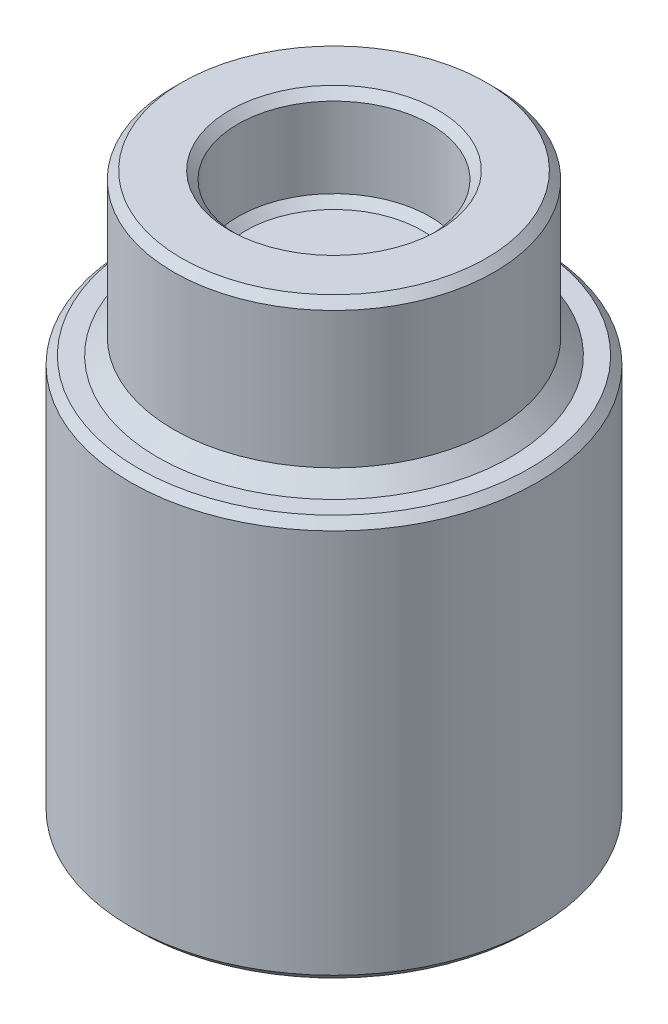
from build123d import *

# Parameters (mm, degrees)
SKETCH1_R                              = 5
BOSS_EXTRUDE1_DEPTH                    = 2
SKETCH1_3_R                            = 5
SKETCH1_3_R_2                          = 3
BOSS_EXTRUDE2_DEPTH                    = 5
CHAMFER1_SIZE                          = 0.25
SKETCH5_R                              = 6.35
BOSS_EXTRUDE4_DEPTH                    = 12.5
F_3_8_0_375_DIAMETER_HOLE1_D           = 9.525
F_3_8_0_375_DIAMETER_HOLE1_DEPTH       = 12.08333524
F_3_8_0_375_DIAMETER_HOLE1_CSINK_D     = 10.795
F_3_8_0_375_DIAMETER_HOLE1_CSINK_ANGLE = 90
F_3_8_0_375_DIAMETER_HOLE1_TIP         = 0.41666476
CHAMFER2_SIZE                          = 0.25
CHAMFER3_SIZE                          = 0.5


with BuildPart() as part:
    # Sketch1 → Boss-Extrude1 (new body)
    with BuildSketch(Plane(origin=(0, 0, 0), x_dir=(1, 0, 0), z_dir=(0, 1, 0))):
        Circle(SKETCH1_R)
    extrude(amount=BOSS_EXTRUDE1_DEPTH)

    # Sketch1_3 → Boss-Extrude2 (add)
    with BuildSketch(Plane(origin=(0, 0, 0), x_dir=(1, 0, 0), z_dir=(0, 1, 0))):
        Circle(SKETCH1_3_R)
        Circle(SKETCH1_3_R_2, mode=Mode.SUBTRACT)
    extrude(amount=BOSS_EXTRUDE2_DEPTH)

    # Chamfer1
    chamfer1_edges = [part.edges().sort_by_distance(p)[0] for p in [
        (-3, 5, 0),
        (-5, 5, 0),
        (-3, 2, 0),
    ]]
    chamfer(chamfer1_edges, length=CHAMFER1_SIZE)

    # Sketch5 → Boss-Extrude4 (add)
    with BuildSketch(Plane(origin=(0, 0, 0), x_dir=(1, 0, 0), z_dir=(0, 1, 0))):
        Circle(SKETCH5_R)
    extrude(amount=-BOSS_EXTRUDE4_DEPTH)

    # 3_8 _0.375_ Diameter Hole1
    with Locations(Plane(origin=(0, -12.5, 0), x_dir=(-1, 0, 0), z_dir=(0, -1, 0))):
        with Locations((0, 0)):
            CounterSinkHole(F_3_8_0_375_DIAMETER_HOLE1_D / 2, F_3_8_0_375_DIAMETER_HOLE1_CSINK_D / 2, depth=F_3_8_0_375_DIAMETER_HOLE1_DEPTH, counter_sink_angle=F_3_8_0_375_DIAMETER_HOLE1_CSINK_ANGLE)
            with Locations((0, 0, -(F_3_8_0_375_DIAMETER_HOLE1_DEPTH + F_3_8_0_375_DIAMETER_HOLE1_TIP / 2))):  # 170° drill point
                Cone(0, F_3_8_0_375_DIAMETER_HOLE1_D / 2, F_3_8_0_375_DIAMETER_HOLE1_TIP, mode=Mode.SUBTRACT)

    # Chamfer2
    chamfer2_edges = [part.edges().sort_by_distance(p)[0] for p in [
        (-6.35, -12.5, 0),
        (-6.35, 0, 0),
    ]]
    chamfer(chamfer2_edges, length=CHAMFER2_SIZE)

    # Chamfer3
    chamfer3_edges = [part.edges().sort_by_distance(p)[0] for p in [
        (-5, 0, 0),
    ]]
    chamfer(chamfer3_edges, length=CHAMFER3_SIZE)


solid = part.part
